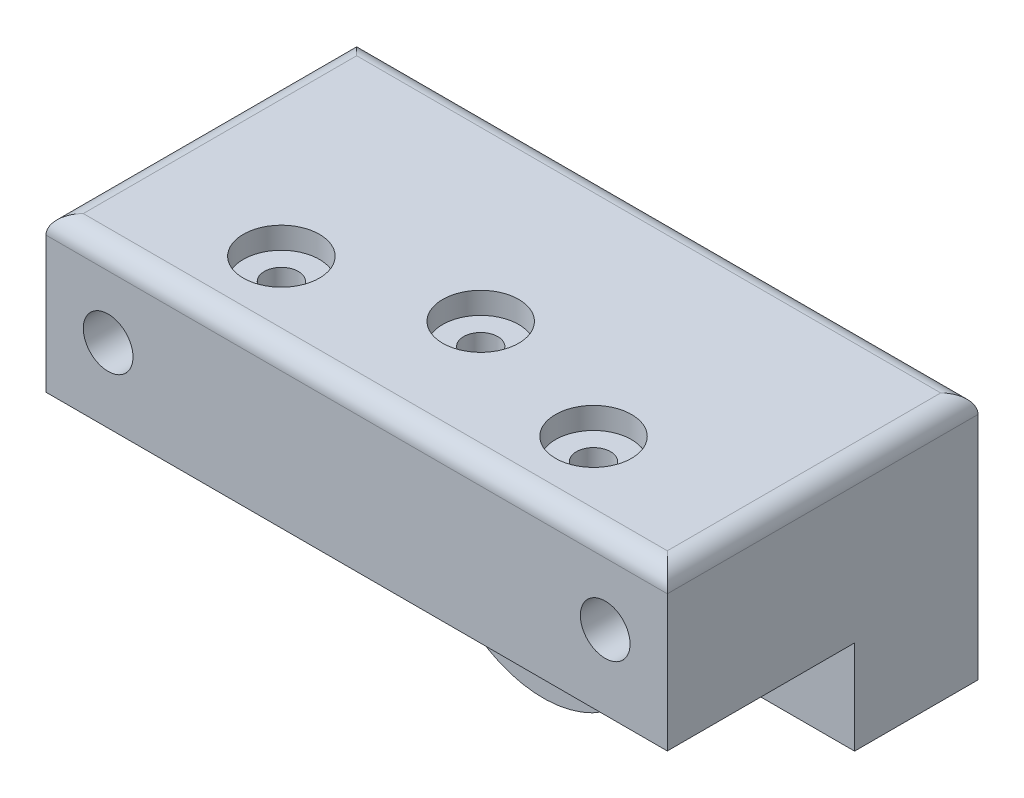
from build123d import *

# Parameters (mm, degrees)
ESBO_O1_W                                            = 100
ESBO_O1_H                                            = 40
ESBO_O1_R                                            = 4
RESSALTO_EXTRUS_O1_DEPTH                             = 50
FILETE1_R                                            = 3
ESBO_O3_W                                            = 30.13686718
ESBO_O3_H                                            = 15.092425978
CORTE_EXTRUS_O1_DEPTH                                = 1
CORTE_EXTRUS_O1_DEPTH_BACK                           = 101
ESBO_O4_R                                            = 17.5
RESSALTO_EXTRUS_O2_DEPTH                             = 20
RESSALTO_EXTRUS_O2_DEPTH_BACK                        = 20
REBAIXO_PARA_PARAFUSO_DE_CABE_A_SEXTAVAD_D           = 5.5
REBAIXO_PARA_PARAFUSO_DE_CABE_A_SEXTAVAD_CBORE_D     = 12.238
REBAIXO_PARA_PARAFUSO_DE_CABE_A_SEXTAVAD_CBORE_DEPTH = 3.5


with BuildPart() as part:
    # Esboço1 → Ressalto-extrusão1 (new body)
    with BuildSketch(Plane.XY.offset(127.860451464)):
        with Locations((-309.31398478, 35)):
            Rectangle(ESBO_O1_W, ESBO_O1_H)
        with Locations((-349.31398478, 42)):
            Circle(ESBO_O1_R, mode=Mode.SUBTRACT)
        with Locations((-269.31398478, 42)):
            Circle(ESBO_O1_R, mode=Mode.SUBTRACT)
    extrude(amount=-RESSALTO_EXTRUS_O1_DEPTH)

    # Filete1
    filete1_edges = [part.edges().sort_by_distance(p)[0] for p in [
        (-309.31398478, 55, 77.860451464),
        (-309.31398478, 55, 127.860451464),
        (-359.31398478, 55, 102.860451464),
        (-259.31398478, 55, 102.860451464),
    ]]
    fillet(filete1_edges, radius=FILETE1_R)

    # Esboço3 → Corte-extrusão1 (cut, two sides)
    with BuildSketch(Plane.ZY.offset(359.31398478)) as corte_extrus_o1_sk:
        with Locations((112.792017874, 22.546212989)):
            Rectangle(ESBO_O3_W, ESBO_O3_H)
    extrude(amount=CORTE_EXTRUS_O1_DEPTH, mode=Mode.SUBTRACT)
    extrude(corte_extrus_o1_sk.sketch, amount=-CORTE_EXTRUS_O1_DEPTH_BACK, mode=Mode.SUBTRACT)

    # Esboço4 → Ressalto-extrusão2 (add, two sides)
    with BuildSketch(Plane(origin=(0, 0, 77.860451464), x_dir=(-1, 0, 0), z_dir=(0, 0, -1))) as ressalto_extrus_o2_sk:
        with Locations((309.31398478, 14.975825016)):
            Circle(ESBO_O4_R)
    extrude(amount=RESSALTO_EXTRUS_O2_DEPTH)
    extrude(ressalto_extrus_o2_sk.sketch, amount=-RESSALTO_EXTRUS_O2_DEPTH_BACK)

    # Rebaixo para parafuso de cabeça sextavada de M51 (through all)
    with Locations(Plane(origin=(0, 55, 0), x_dir=(1, 0, 0), z_dir=(0, 1, 0))):
        with Locations((-284.195309224, -114.860451464), (-334.432660336, -114.860451464), (-309.31398478, -107.896538756)):
            CounterBoreHole(REBAIXO_PARA_PARAFUSO_DE_CABE_A_SEXTAVAD_D / 2, REBAIXO_PARA_PARAFUSO_DE_CABE_A_SEXTAVAD_CBORE_D / 2, REBAIXO_PARA_PARAFUSO_DE_CABE_A_SEXTAVAD_CBORE_DEPTH)


solid = part.part
